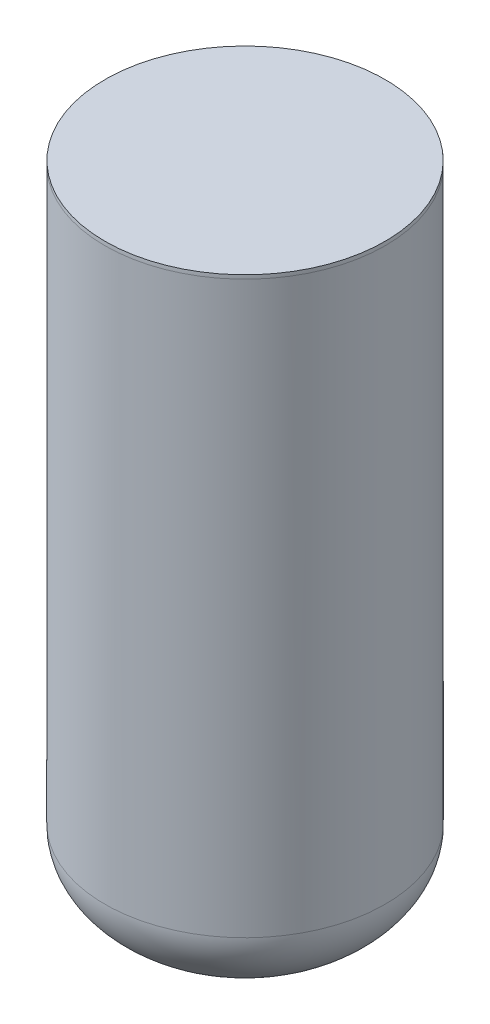
from build123d import *

# Parameters (mm, degrees)
SKETCH2_R                = 95.25
BOSS_EXTRUDE1_DEPTH      = 387.35
SKETCH6_R                = 95.25
F_7_PERCENT_ULLAGE_DEPTH = 57.15


with BuildPart() as part:
    # Sketch2 → Boss-Extrude1 (new body)
    with BuildSketch(Plane(origin=(0, 0, 0), x_dir=(1, 0, 0), z_dir=(0, 1, 0))):
        Circle(SKETCH2_R)
    extrude(amount=BOSS_EXTRUDE1_DEPTH)

    # Sketch3 → Revolve2 (revolve)
    with BuildSketch(Plane(origin=(0, 0, 0), x_dir=(0, 0, -1), z_dir=(1, 0, 0))):
        with BuildLine():
            Line((0, 447.04), (0, 387.35))
            Line((0, 387.35), (95.25, 387.35))
            add(Edge.make_bspline(
                [(95.25, 387.35), (95.25, 447.04), (0, 447.04)],
                knots=[3.141592654, 3.141592654, 3.141592654, 4.71238898, 4.71238898, 4.71238898], degree=2, weights=[1, 0.707106781, 1]))
        make_face()
    revolve(axis=Axis((0, 447.04, 0), (0, -1, 0)))

    # Sketch4 → Revolve3 (revolve)
    with BuildSketch(Plane(origin=(0, 0, 0), x_dir=(0, 0, -1), z_dir=(1, 0, 0))):
        with BuildLine():
            Line((0, -61.214), (0, 0))
            Line((0, 0), (95.25, 0))
            add(Edge.make_bspline(
                [(0, -61.214), (95.25, -61.214), (95.25, 0)],
                knots=[4.71238898, 4.71238898, 4.71238898, 6.283185307, 6.283185307, 6.283185307], degree=2, weights=[1, 0.707106781, 1]))
        make_face()
    revolve(axis=Axis((0, -61.214, 0), (0, 1, 0)))

    # Sketch6 → 7 Percent Ullage (cut)
    with BuildSketch(Plane(origin=(0, 447.04, 0), x_dir=(1, 0, 0), z_dir=(0, 1, 0))):
        Circle(SKETCH6_R)
    extrude(amount=-F_7_PERCENT_ULLAGE_DEPTH, mode=Mode.SUBTRACT)


solid = part.part
